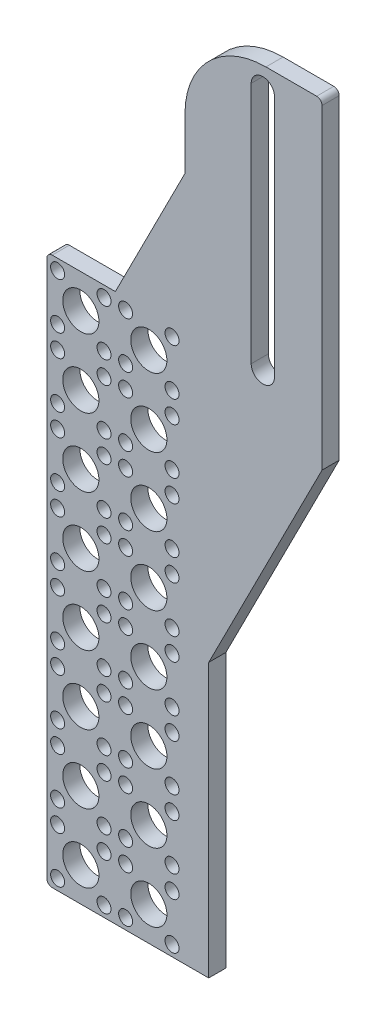
from build123d import *

# Parameters (mm, degrees)
SKETCH2_R           = 1.2954
SKETCH2_R_2         = 3.35
BOSS_EXTRUDE1_DEPTH = 3.175
FILLET1_R           = 15
FILLET2_R           = 1


with BuildPart() as part:
    # Sketch2 → Boss-Extrude1 (new body)
    with BuildSketch(Plane.XY):
        Polygon((-115.54, -32.181), (-128.24, -32.181), (-128.24, -133.681), (-98.24, -133.681), (-98.24, -83.029837209), (-77.24, -41.681), (-77.24, 17.819), (-102.64, 17.819), (-102.64, -6.781), align=None)
        with BuildLine():
            Line((-90.372732921, -31.181), (-90.372732921, 13.819))
            ThreePointArc((-90.372732921, 13.819), (-88.212732921, 15.979), (-86.052732921, 13.819))
            Line((-86.052732921, 13.819), (-86.052732921, -31.181))
            ThreePointArc((-86.052732921, -31.181), (-88.212732921, -33.341), (-90.372732921, -31.181))
        make_face(mode=Mode.SUBTRACT)
        with Locations((-126.24, -131.681)):
            Circle(SKETCH2_R, mode=Mode.SUBTRACT)
        with Locations((-121.94, -127.381)):
            Circle(SKETCH2_R_2, mode=Mode.SUBTRACT)
        with Locations((-126.24, -123.081)):
            Circle(SKETCH2_R, mode=Mode.SUBTRACT)
        with Locations((-126.24, -118.981)):
            Circle(SKETCH2_R, mode=Mode.SUBTRACT)
        with Locations((-117.64, -131.681)):
            Circle(SKETCH2_R, mode=Mode.SUBTRACT)
        with Locations((-117.64, -123.081)):
            Circle(SKETCH2_R, mode=Mode.SUBTRACT)
        with Locations((-117.64, -118.981)):
            Circle(SKETCH2_R, mode=Mode.SUBTRACT)
        with Locations((-126.24, -110.381)):
            Circle(SKETCH2_R, mode=Mode.SUBTRACT)
        with Locations((-126.24, -106.281)):
            Circle(SKETCH2_R, mode=Mode.SUBTRACT)
        with Locations((-121.94, -114.681)):
            Circle(SKETCH2_R_2, mode=Mode.SUBTRACT)
        with Locations((-126.24, -97.681)):
            Circle(SKETCH2_R, mode=Mode.SUBTRACT)
        with Locations((-121.94, -101.981)):
            Circle(SKETCH2_R_2, mode=Mode.SUBTRACT)
        with Locations((-117.64, -110.381)):
            Circle(SKETCH2_R, mode=Mode.SUBTRACT)
        with Locations((-117.64, -106.281)):
            Circle(SKETCH2_R, mode=Mode.SUBTRACT)
        with Locations((-117.64, -97.681)):
            Circle(SKETCH2_R, mode=Mode.SUBTRACT)
        with Locations((-113.64, -131.681)):
            Circle(SKETCH2_R, mode=Mode.SUBTRACT)
        with Locations((-109.34, -127.381)):
            Circle(SKETCH2_R_2, mode=Mode.SUBTRACT)
        with Locations((-113.64, -123.081)):
            Circle(SKETCH2_R, mode=Mode.SUBTRACT)
        with Locations((-113.64, -118.981)):
            Circle(SKETCH2_R, mode=Mode.SUBTRACT)
        with Locations((-105.04, -131.681)):
            Circle(SKETCH2_R, mode=Mode.SUBTRACT)
        with Locations((-105.04, -123.081)):
            Circle(SKETCH2_R, mode=Mode.SUBTRACT)
        with Locations((-105.04, -118.981)):
            Circle(SKETCH2_R, mode=Mode.SUBTRACT)
        with Locations((-113.64, -110.381)):
            Circle(SKETCH2_R, mode=Mode.SUBTRACT)
        with Locations((-113.64, -106.281)):
            Circle(SKETCH2_R, mode=Mode.SUBTRACT)
        with Locations((-109.34, -114.681)):
            Circle(SKETCH2_R_2, mode=Mode.SUBTRACT)
        with Locations((-113.64, -97.681)):
            Circle(SKETCH2_R, mode=Mode.SUBTRACT)
        with Locations((-109.34, -101.981)):
            Circle(SKETCH2_R_2, mode=Mode.SUBTRACT)
        with Locations((-105.04, -110.381)):
            Circle(SKETCH2_R, mode=Mode.SUBTRACT)
        with Locations((-105.04, -106.281)):
            Circle(SKETCH2_R, mode=Mode.SUBTRACT)
        with Locations((-105.04, -97.681)):
            Circle(SKETCH2_R, mode=Mode.SUBTRACT)
        with Locations((-126.24, -93.581)):
            Circle(SKETCH2_R, mode=Mode.SUBTRACT)
        with Locations((-121.94, -89.281)):
            Circle(SKETCH2_R_2, mode=Mode.SUBTRACT)
        with Locations((-126.24, -84.981)):
            Circle(SKETCH2_R, mode=Mode.SUBTRACT)
        with Locations((-126.24, -80.881)):
            Circle(SKETCH2_R, mode=Mode.SUBTRACT)
        with Locations((-117.64, -93.581)):
            Circle(SKETCH2_R, mode=Mode.SUBTRACT)
        with Locations((-117.64, -84.981)):
            Circle(SKETCH2_R, mode=Mode.SUBTRACT)
        with Locations((-117.64, -80.881)):
            Circle(SKETCH2_R, mode=Mode.SUBTRACT)
        with Locations((-126.24, -72.281)):
            Circle(SKETCH2_R, mode=Mode.SUBTRACT)
        with Locations((-126.24, -68.181)):
            Circle(SKETCH2_R, mode=Mode.SUBTRACT)
        with Locations((-121.94, -76.581)):
            Circle(SKETCH2_R_2, mode=Mode.SUBTRACT)
        with Locations((-126.24, -59.581)):
            Circle(SKETCH2_R, mode=Mode.SUBTRACT)
        with Locations((-121.94, -63.881)):
            Circle(SKETCH2_R_2, mode=Mode.SUBTRACT)
        with Locations((-117.64, -72.281)):
            Circle(SKETCH2_R, mode=Mode.SUBTRACT)
        with Locations((-117.64, -68.181)):
            Circle(SKETCH2_R, mode=Mode.SUBTRACT)
        with Locations((-117.64, -59.581)):
            Circle(SKETCH2_R, mode=Mode.SUBTRACT)
        with Locations((-113.64, -93.581)):
            Circle(SKETCH2_R, mode=Mode.SUBTRACT)
        with Locations((-109.34, -89.281)):
            Circle(SKETCH2_R_2, mode=Mode.SUBTRACT)
        with Locations((-113.64, -84.981)):
            Circle(SKETCH2_R, mode=Mode.SUBTRACT)
        with Locations((-113.64, -80.881)):
            Circle(SKETCH2_R, mode=Mode.SUBTRACT)
        with Locations((-105.04, -93.581)):
            Circle(SKETCH2_R, mode=Mode.SUBTRACT)
        with Locations((-105.04, -84.981)):
            Circle(SKETCH2_R, mode=Mode.SUBTRACT)
        with Locations((-105.04, -80.881)):
            Circle(SKETCH2_R, mode=Mode.SUBTRACT)
        with Locations((-113.64, -72.281)):
            Circle(SKETCH2_R, mode=Mode.SUBTRACT)
        with Locations((-113.64, -68.181)):
            Circle(SKETCH2_R, mode=Mode.SUBTRACT)
        with Locations((-109.34, -76.581)):
            Circle(SKETCH2_R_2, mode=Mode.SUBTRACT)
        with Locations((-113.64, -59.581)):
            Circle(SKETCH2_R, mode=Mode.SUBTRACT)
        with Locations((-109.34, -63.881)):
            Circle(SKETCH2_R_2, mode=Mode.SUBTRACT)
        with Locations((-105.04, -72.281)):
            Circle(SKETCH2_R, mode=Mode.SUBTRACT)
        with Locations((-105.04, -68.181)):
            Circle(SKETCH2_R, mode=Mode.SUBTRACT)
        with Locations((-105.04, -59.581)):
            Circle(SKETCH2_R, mode=Mode.SUBTRACT)
        with Locations((-126.24, -55.481)):
            Circle(SKETCH2_R, mode=Mode.SUBTRACT)
        with Locations((-121.94, -51.181)):
            Circle(SKETCH2_R_2, mode=Mode.SUBTRACT)
        with Locations((-126.24, -46.881)):
            Circle(SKETCH2_R, mode=Mode.SUBTRACT)
        with Locations((-126.24, -42.781)):
            Circle(SKETCH2_R, mode=Mode.SUBTRACT)
        with Locations((-117.64, -55.481)):
            Circle(SKETCH2_R, mode=Mode.SUBTRACT)
        with Locations((-117.64, -46.881)):
            Circle(SKETCH2_R, mode=Mode.SUBTRACT)
        with Locations((-117.64, -42.781)):
            Circle(SKETCH2_R, mode=Mode.SUBTRACT)
        with Locations((-126.24, -34.181)):
            Circle(SKETCH2_R, mode=Mode.SUBTRACT)
        with Locations((-121.94, -38.481)):
            Circle(SKETCH2_R_2, mode=Mode.SUBTRACT)
        with Locations((-117.64, -34.181)):
            Circle(SKETCH2_R, mode=Mode.SUBTRACT)
        with Locations((-113.64, -55.481)):
            Circle(SKETCH2_R, mode=Mode.SUBTRACT)
        with Locations((-109.34, -51.181)):
            Circle(SKETCH2_R_2, mode=Mode.SUBTRACT)
        with Locations((-113.64, -46.881)):
            Circle(SKETCH2_R, mode=Mode.SUBTRACT)
        with Locations((-113.64, -42.781)):
            Circle(SKETCH2_R, mode=Mode.SUBTRACT)
        with Locations((-105.04, -55.481)):
            Circle(SKETCH2_R, mode=Mode.SUBTRACT)
        with Locations((-105.04, -46.881)):
            Circle(SKETCH2_R, mode=Mode.SUBTRACT)
        with Locations((-105.04, -42.781)):
            Circle(SKETCH2_R, mode=Mode.SUBTRACT)
        with Locations((-113.64, -34.181)):
            Circle(SKETCH2_R, mode=Mode.SUBTRACT)
        with Locations((-109.34, -38.481)):
            Circle(SKETCH2_R_2, mode=Mode.SUBTRACT)
        with Locations((-105.04, -34.181)):
            Circle(SKETCH2_R, mode=Mode.SUBTRACT)
    extrude(amount=BOSS_EXTRUDE1_DEPTH)

    # Fillet1
    fillet1_edges = [part.edges().sort_by_distance(p)[0] for p in [
        (-102.64, 17.819, 1.5875),
    ]]
    fillet(fillet1_edges, radius=FILLET1_R)

    # Fillet2
    fillet2_edges = [part.edges().sort_by_distance(p)[0] for p in [
        (-128.24, -133.681, 1.5875),
        (-128.24, -32.181, 1.5875),
        (-77.24, 17.819, 1.5875),
    ]]
    fillet(fillet2_edges, radius=FILLET2_R)


solid = part.part
